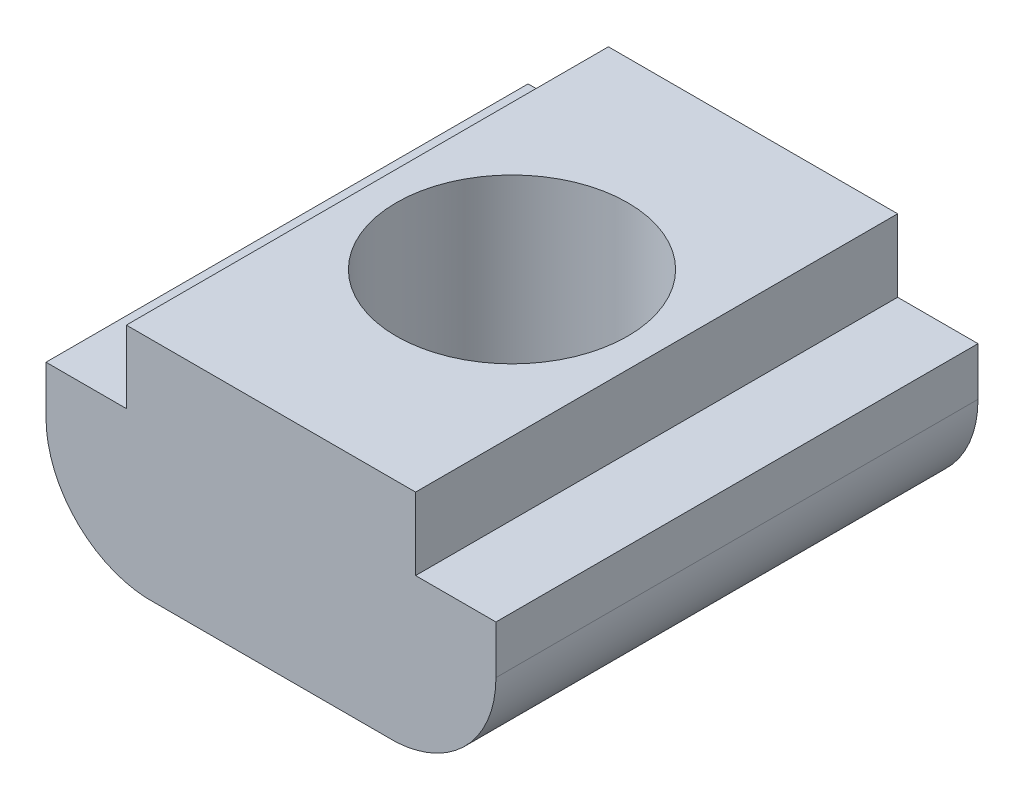
from build123d import *

# Parameters (mm, degrees)
EXTRUDE_1_DEPTH    = 10
HOLE_WIZARD_M6_4_D = 4.8


with BuildPart() as part:
    # 草图1 → 凸台-拉伸1 (new body)
    with BuildSketch(Plane.XY):
        with BuildLine():
            Line((3, 3), (-3, 3))
            Line((-3, 3), (-3, 1.5))
            Line((-3, 1.5), (-4.666746731, 1.5))
            Line((-4.666746731, 1.5), (-4.666746731, 0.5))
            ThreePointArc((-4.666746731, 0.5), (-4.068683171, -1.006990331), (-2.6, -1.69377241))
            Line((-2.6, -1.69377241), (2.6, -1.69377241))
            ThreePointArc((2.6, -1.69377241), (4.068683171, -1.006990331), (4.666746731, 0.5))
            Line((4.666746731, 0.5), (4.666746731, 1.5))
            Line((4.666746731, 1.5), (3, 1.5))
            Line((3, 1.5), (3, 3))
        make_face()
    extrude(amount=EXTRUDE_1_DEPTH)

    # M6 螺纹孔4 (through all)
    with Locations(Plane(origin=(0, 3, 0), x_dir=(1, 0, 0), z_dir=(0, 1, 0))):
        with Locations((0, -5)):
            Hole(HOLE_WIZARD_M6_4_D / 2)


with BuildPart() as part_1:
    # Move Body 1: moved
    add(part.part.moved(Location((0, 0, -5))))


solid = part_1.part
